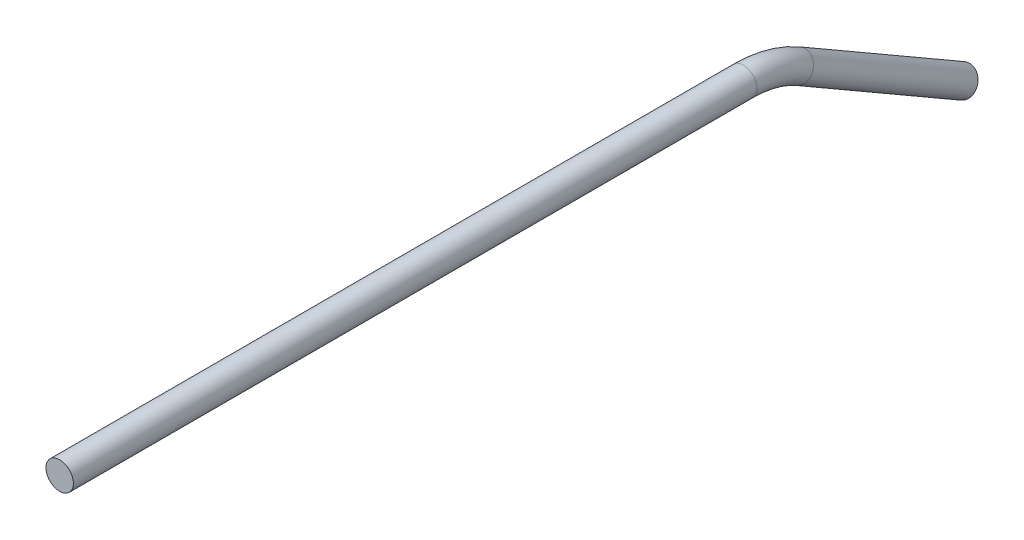
from build123d import *

# Parameters (mm, degrees)
SKETCH2_R = 3.175


with BuildPart() as part:
    # Sweep1: sweep along a path in Sketch4
    with BuildLine(Plane(origin=(0, 0, 0), x_dir=(0, 0, -1), z_dir=(1, 0, 0))) as sweep1_path:
        Line((0, 0), (158.294090512, 0))
        ThreePointArc((158.294090512, 0), (164.868094258, -0.865484012), (170.994090512, -3.402954744))
        Line((170.994090512, -3.402954744), (209.094090512, -25.4))
    # Sketch2 → Sweep1 (sweep)
    with BuildSketch(Plane.XY):
        Circle(SKETCH2_R)
    sweep(path=sweep1_path.line)


solid = part.part
